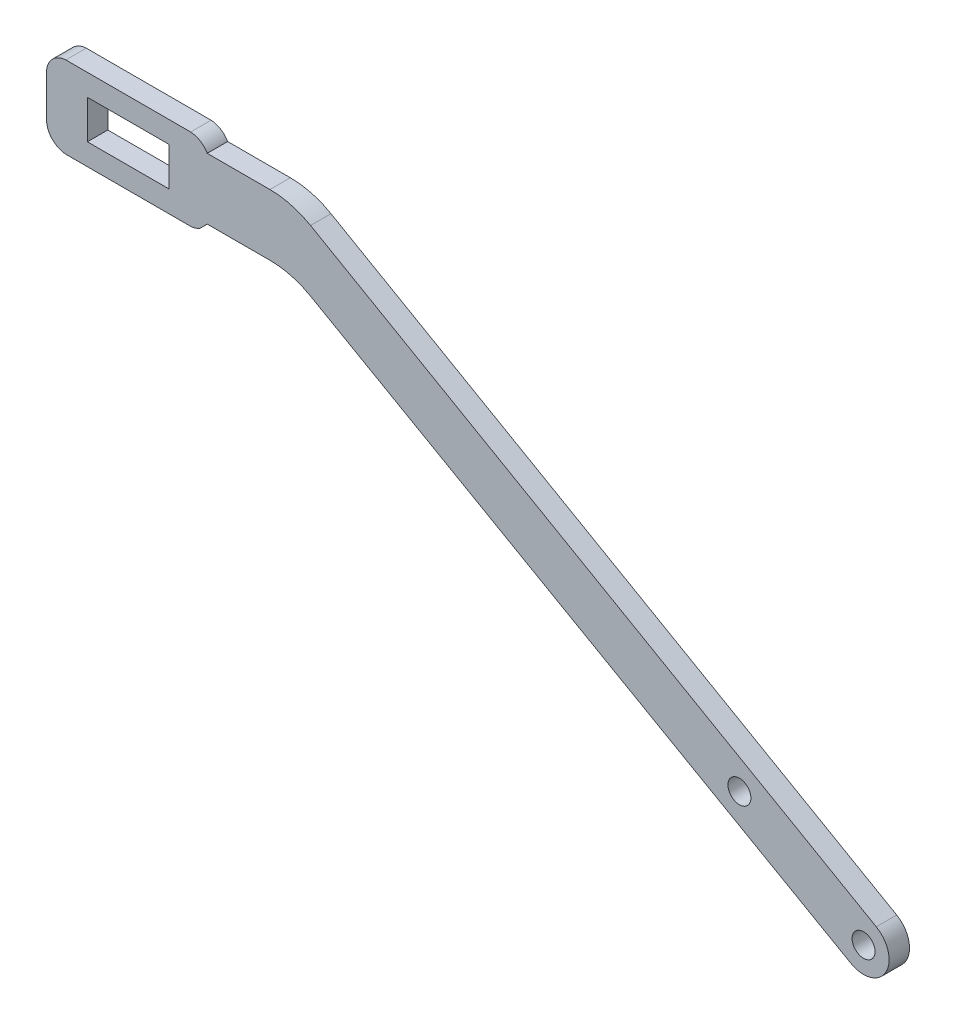
from build123d import *

# Parameters (mm, degrees)
SKETCH1_R                       = 1.7859375
SKETCH1_W                       = 12.7
SKETCH1_H                       = 5.9944
BOSS_EXTRUDE1_DEPTH             = 3.175
FILLET2_R                       = 12.7
F_9_64_0_14063_DIAMETER_HOLE1_D = 3.572002


with BuildPart() as part:
    # Sketch1 → Boss-Extrude1 (new body)
    with BuildSketch(Plane.XY):
        with BuildLine():
            Line((-25.595614794, 12.127914856), (-24.431663343, 13.29684081))
            Line((-24.431663343, 13.29684081), (-11.306294, 13.29684081))
            Line((-11.306294, 13.29684081), (6.117359384, 3.377856252))
            Line((6.117359384, 3.377856252), (12.411791243, -0.205454953))
            Line((12.411791243, -0.205454953), (75.625928444, -36.192170077))
            ThreePointArc((75.625928444, -36.192170077), (81.03522907, -34.712213349), (79.564057068, -29.300516931))
            Line((79.564057068, -29.300516931), (-11.306294, 22.82184081))
            Line((-11.306294, 22.82184081), (-24.431663343, 22.82184081))
            ThreePointArc((-24.431663343, 22.82184081), (-25.519216943, 23.940247646), (-27.007802046, 24.406853559))
            Line((-27.007802046, 24.406853559), (-46.413402046, 24.406853559))
            ThreePointArc((-46.413402046, 24.406853559), (-48.546190424, 23.416669154), (-49.415576549, 21.231853559))
            Line((-49.415576549, 21.231853559), (-49.415576549, 14.881853559))
            ThreePointArc((-49.415576549, 14.881853559), (-48.546190424, 12.697037963), (-46.413402046, 11.706853559))
            Line((-46.413402046, 11.706853559), (-27.007802046, 11.706853559))
            ThreePointArc((-27.007802046, 11.706853559), (-26.27698161, 11.834453561), (-25.595614794, 12.127914856))
        make_face()
        with Locations((77.589397954, -32.743146441)):
            Circle(SKETCH1_R, mode=Mode.SUBTRACT)
        with Locations((-36.710602046, 18.056853559)):
            Rectangle(SKETCH1_W, SKETCH1_H, mode=Mode.SUBTRACT)
    extrude(amount=BOSS_EXTRUDE1_DEPTH)

    # Fillet2
    fillet2_edges = [part.edges().sort_by_distance(p)[0] for p in [
        (-11.306294, 22.82184081, 1.5875),
        (-11.306294, 13.29684081, 1.5875),
    ]]
    fillet(fillet2_edges, radius=FILLET2_R)

    # 9/64 (0.14063) Diameter Hole1 (through all)
    with Locations(Plane.XY.offset(3.175)):
        with Locations((58.292743709, -21.716371758)):
            Hole(F_9_64_0_14063_DIAMETER_HOLE1_D / 2)


solid = part.part
